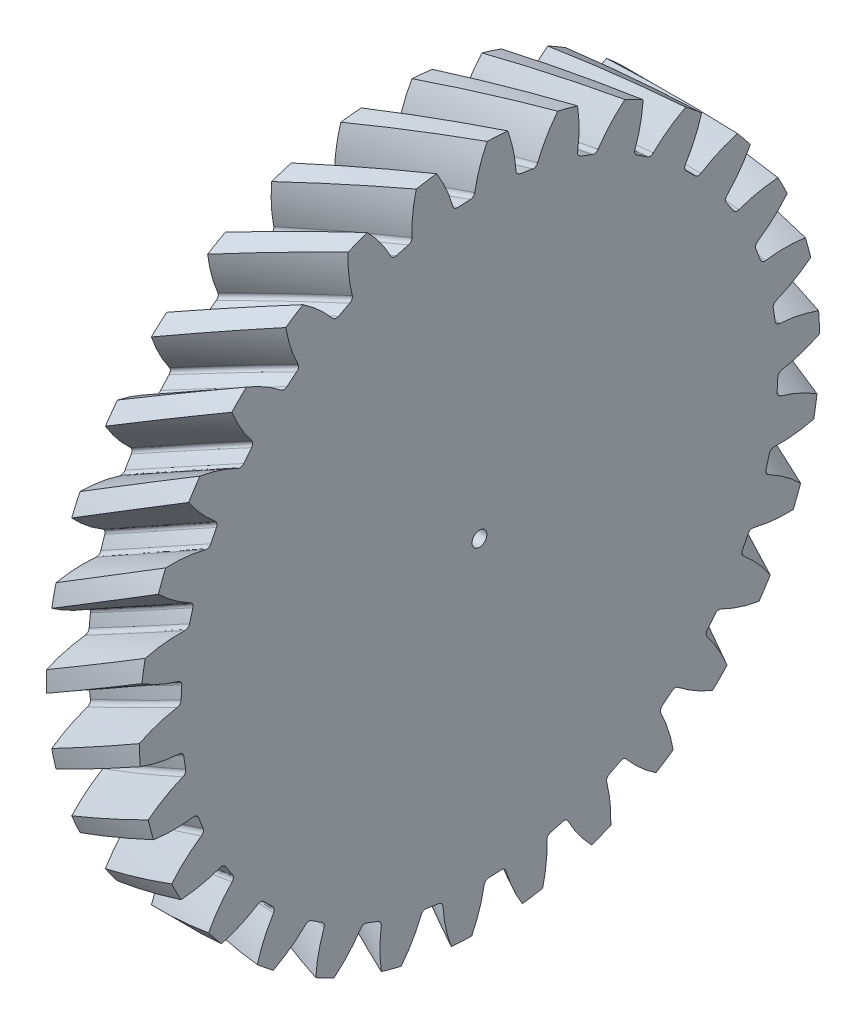
from build123d import *

# Parameters (mm, degrees)
BASPROSKE_W            = 5
BASPROSKE_H            = 18.320508076
TOOTHCUTLH_PITCH       = 199.378355401
TOOTHCUTLH_HEIGHT      = 5
TOOTHCUTLH_RADIUS      = 18.320508076
TOOTHCUTLH_START_ANGLE = -90
TEETHCUTSLH_COUNT      = 30
TEETHCUTSLH_ANGLE      = 348
BORSKE_R               = 0.4
BORE_DEPTH             = 62.5000025


with BuildPart() as part:
    # BasProSke → Base-Revolve (revolve)
    with BuildSketch(Plane(origin=(0, 0, 0), x_dir=(1, 0, 0), z_dir=(0, 1, 0)), mode=Mode.PRIVATE) as base_revolve_sk:
        with Locations((2.5, 9.160254038)):
            Rectangle(BASPROSKE_W, BASPROSKE_H)
    revolve(base_revolve_sk.sketch.rotate(Axis((-10, 0, 0), (1, 0, 0)), 180), axis=Axis((-10, 0, 0), (1, 0, 0)))

    # ToothCutLH: sweep along a helix
    with BuildLine() as toothcutlh_path:
        add(Helix(TOOTHCUTLH_PITCH, TOOTHCUTLH_HEIGHT, TOOTHCUTLH_RADIUS, center=(0, 0, 0), direction=(1, 0, 0), lefthand=True, mode=Mode.PRIVATE).rotate(Axis((0, 0, 0), (1, 0, 0)), TOOTHCUTLH_START_ANGLE))
    # TooCutSkeRH_3 → ToothCutLH (sweep, cut)
    with BuildSketch(Plane(origin=(0, 0, 0), x_dir=(0, 0, -1), z_dir=(1, 0, 0))):
        with BuildLine():
            ThreePointArc((0.339990932, 16.066911215), (0, 16.070508076), (-0.339990932, 16.066911215))
            ThreePointArc((-0.339990932, 16.066911215), (-0.499727416, 16.11998254), (-0.59001654, 16.262039515))
            ThreePointArc((-0.59001654, 16.262039515), (-1.021822674, 17.579207163), (-1.68864971, 18.794414495))
            ThreePointArc((-1.68864971, 18.794414495), (0, 18.870123318), (1.68864971, 18.794414495))
            ThreePointArc((1.68864971, 18.794414495), (1.021822674, 17.579207163), (0.59001654, 16.262039515))
            ThreePointArc((0.59001654, 16.262039515), (0.499727416, 16.11998254), (0.339990932, 16.066911215))
        make_face()
    toothcutlh = sweep(path=toothcutlh_path.line, is_frenet=True, mode=Mode.SUBTRACT)

    # TeethCutsLH: ToothCutLH ×30 about axis
    teethcutslh_axis = Axis((-10, 0, 0), (1, 0, 0))
    for i in range(1, TEETHCUTSLH_COUNT):
        add(toothcutlh.rotate(teethcutslh_axis, i * TEETHCUTSLH_ANGLE / (TEETHCUTSLH_COUNT - 1)), mode=Mode.SUBTRACT)

    # BorSke → Bore (cut, symmetric)
    with BuildSketch(Plane(origin=(0, 0, 0), x_dir=(0, 0, -1), z_dir=(1, 0, 0))):
        with Locations(Location((0, 0, 0), (0, 0, 180))):
            Circle(BORSKE_R)
    extrude(amount=BORE_DEPTH, both=True, mode=Mode.SUBTRACT)


solid = part.part
